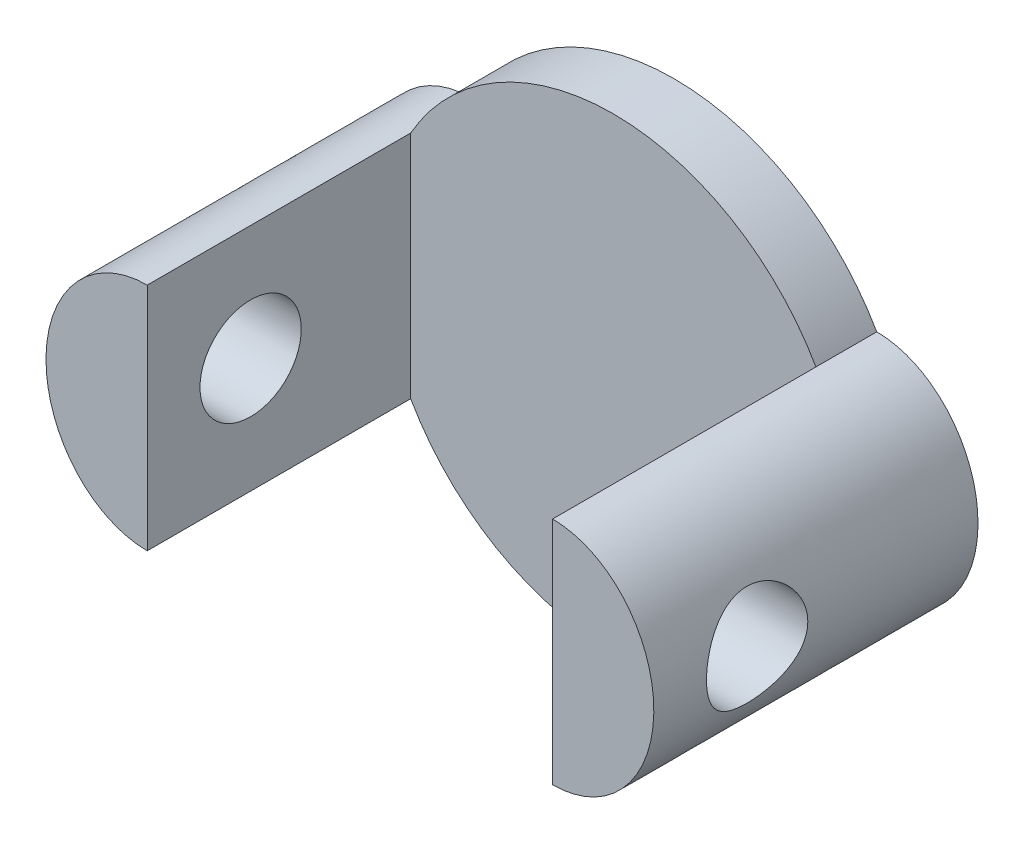
from build123d import *

# Parameters (mm, degrees)
BOSS_EXTRUDE1_DEPTH     = 160
SKETCH3_W               = 200
SKETCH3_H               = 247.224329698
CUT_EXTRUDE1_DEPTH      = 130
SKETCH4_R               = 25
CUT_EXTRUDE2_DEPTH      = 251.0000001
CUT_EXTRUDE2_DEPTH_BACK = 51.0000001


with BuildPart() as part:
    # Sketch1 → Boss-Extrude1 (new body)
    with BuildSketch(Plane.XY):
        with BuildLine():
            ThreePointArc((-100, -56.789083458), (0, -115), (100, -56.789083458))
            add(Edge.make_bspline(
                [(100, -56.789083458), (150, -56.789083458), (150, 0), (150, 56.789083458), (100, 56.789083458)],
                knots=[3.141592654, 3.141592654, 3.141592654, 4.71238898, 4.71238898, 6.283185307, 6.283185307, 6.283185307], degree=2, weights=[1, 0.707106781, 1, 0.707106781, 1]))
            ThreePointArc((100, 56.789083458), (0, 115), (-100, 56.789083458))
            add(Edge.make_bspline(
                [(-100, 56.789083458), (-150, 56.789083458), (-150, 0), (-150, -56.789083458), (-100, -56.789083458)],
                knots=[3.141592654, 3.141592654, 3.141592654, 4.71238898, 4.71238898, 6.283185307, 6.283185307, 6.283185307], degree=2, weights=[1, 0.707106781, 1, 0.707106781, 1]))
        make_face()
    extrude(amount=BOSS_EXTRUDE1_DEPTH)

    # Sketch3 → Cut-Extrude1 (cut)
    with BuildSketch(Plane.XY.offset(160)):
        Rectangle(SKETCH3_W, SKETCH3_H)
    extrude(amount=-CUT_EXTRUDE1_DEPTH, mode=Mode.SUBTRACT)

    # Sketch4 → Cut-Extrude2 (cut, two sides)
    with BuildSketch(Plane(origin=(-100, 0, 0), x_dir=(0, 0, -1), z_dir=(1, 0, 0))) as cut_extrude2_sk:
        with Locations((-109, 0)):
            Circle(SKETCH4_R)
    extrude(amount=CUT_EXTRUDE2_DEPTH, mode=Mode.SUBTRACT)
    extrude(cut_extrude2_sk.sketch, amount=-CUT_EXTRUDE2_DEPTH_BACK, mode=Mode.SUBTRACT)


solid = part.part
